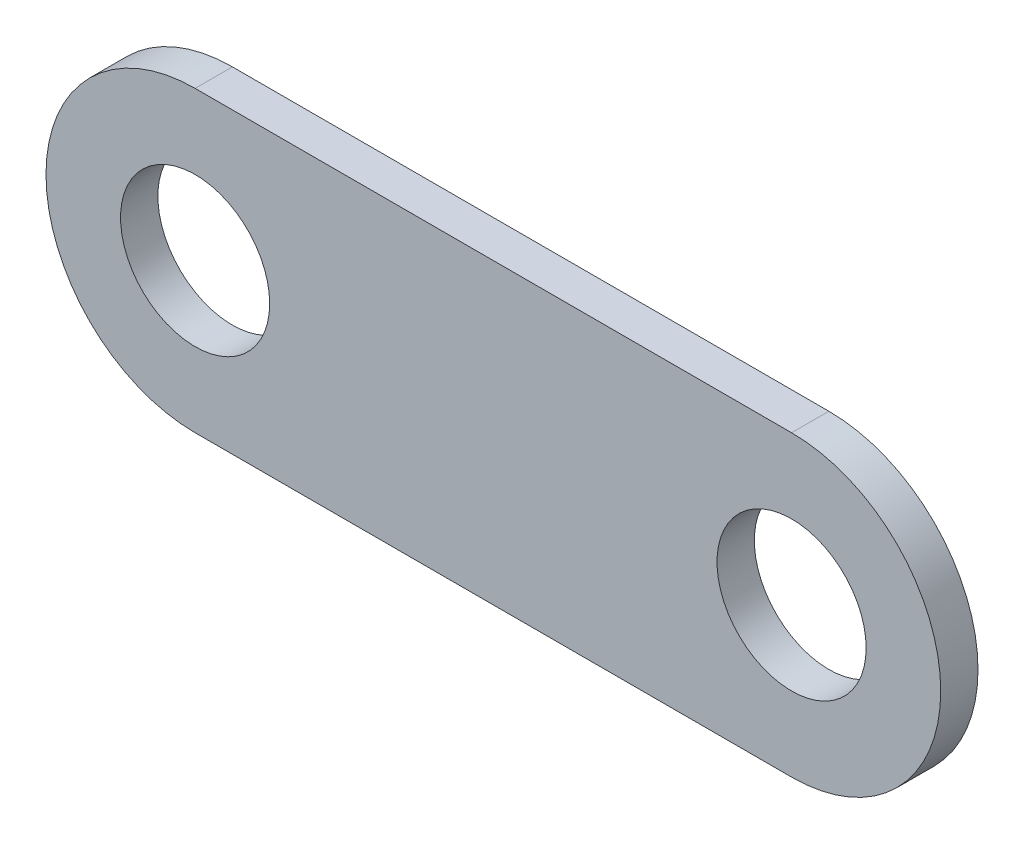
from build123d import *

# Parameters (mm, degrees)
EXTRUDE1_DEPTH     = 5
SKETCH2_R          = 10
CUT_EXTRUDE1_DEPTH = 6


with BuildPart() as part:
    # Sketch1 → Extrude1 (new body)
    with BuildSketch(Plane.XY):
        with BuildLine():
            Line((51.513050076, 21.557056146), (-28.486949924, 21.557056146))
            ThreePointArc((-28.486949924, 21.557056146), (-48.486949924, 1.557056146), (-28.486949924, -18.442943854))
            Line((-28.486949924, -18.442943854), (51.513050076, -18.442943854))
            ThreePointArc((51.513050076, -18.442943854), (71.513050076, 1.557056146), (51.513050076, 21.557056146))
        make_face()
    extrude(amount=EXTRUDE1_DEPTH)

    # Sketch2 → Cut-Extrude1 (cut, through all)
    with BuildSketch(Plane.XY.offset(5)):
        with Locations((-28.486949924, 1.557056146)):
            Circle(SKETCH2_R)
        with Locations((51.513050076, 1.557056146)):
            Circle(SKETCH2_R)
    extrude(amount=-CUT_EXTRUDE1_DEPTH, mode=Mode.SUBTRACT)


solid = part.part
